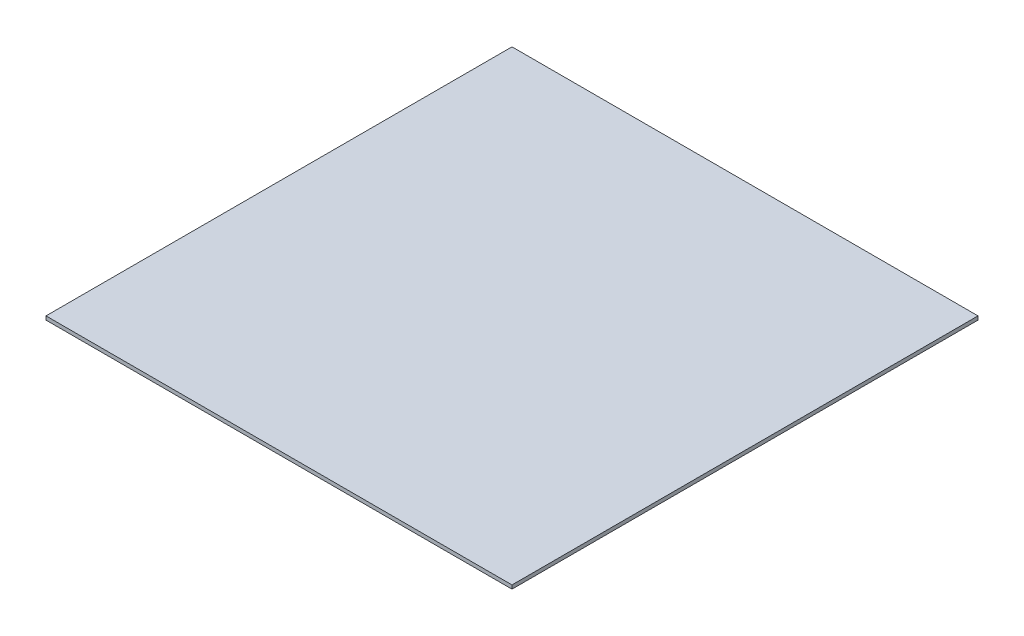
from build123d import *

# Parameters (mm, degrees)
ESQUISSE1_W        = 505
ESQUISSE1_H        = 505
BOSS_EXTRU_1_DEPTH = 4


with BuildPart() as part:
    # Esquisse1 → Boss.-Extru.1 (new body)
    with BuildSketch(Plane(origin=(0, 0, 0), x_dir=(1, 0, 0), z_dir=(0, 1, 0))):
        Rectangle(ESQUISSE1_W, ESQUISSE1_H)
    extrude(amount=BOSS_EXTRU_1_DEPTH)


solid = part.part
